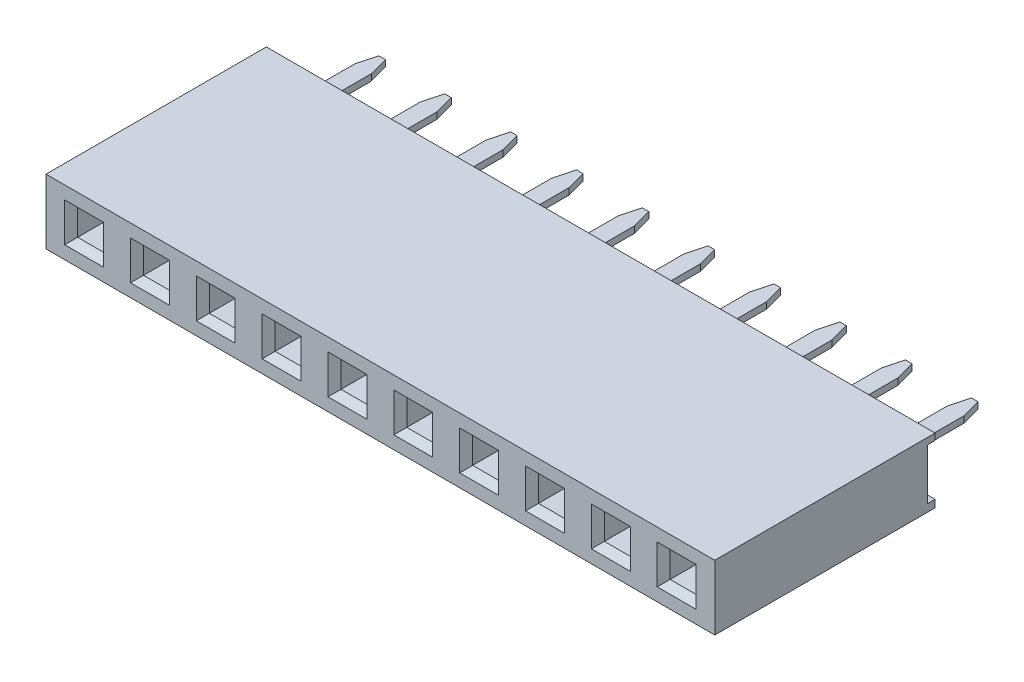
from build123d import *

# Parameters (mm, degrees)
SKETCH1_W                  = 25.8
SKETCH1_H                  = 2.5
BOSS_EXTRUDE1_DEPTH        = 8.5
SKETCH2_W                  = 1
SKETCH2_H                  = 1
CUT_EXTRUDE1_DEPTH         = 2.25
CHAMFER1_SIZE              = 0.25
SKETCH3_W                  = 0.3
SKETCH3_H                  = 1.963850618
CUT_EXTRUDE2_DEPTH         = 26.8
SKETCH4_W                  = 0.65
SKETCH4_H                  = 3.3
BOSS_EXTRUDE2_DEPTH        = 0.125
CHAMFER2_SIZE              = 0.2
CHAMFER2_SIZE2             = 0.746410162
LPATTERN4_COUNT            = 10
LPATTERN4_PITCH            = 2.54
LPATTERN5_COUNT            = 10
LPATTERN5_PITCH            = 2.54
CHAMFER1_OF_LPATTERN5_SIZE = 0.25


with BuildPart() as part:
    # Sketch1 → Boss-Extrude1 (new body)
    with BuildSketch(Plane.XY):
        with Locations((12.9, 1.25)):
            Rectangle(SKETCH1_W, SKETCH1_H)
    extrude(amount=BOSS_EXTRUDE1_DEPTH)

    # Sketch2 → Cut-Extrude1 (cut)
    with BuildSketch(Plane.XY.offset(8.5)):
        with Locations((1.47, 1.25)):
            Rectangle(SKETCH2_W, SKETCH2_H)
    cut_extrude1 = extrude(amount=-CUT_EXTRUDE1_DEPTH, mode=Mode.SUBTRACT)

    # Chamfer1
    chamfer1_edges = [part.edges().sort_by_distance(p)[0] for p in [
        (0.97, 1.25, 8.5),
        (1.47, 0.75, 8.5),
        (1.97, 1.25, 8.5),
        (1.47, 1.75, 8.5),
    ]]
    chamfer(chamfer1_edges, length=CHAMFER1_SIZE)

    # Sketch3 → Cut-Extrude2 (cut, through all)
    with BuildSketch(Plane.ZY):
        with Locations((0.15, 1.268074691)):
            Rectangle(SKETCH3_W, SKETCH3_H)
    extrude(amount=-CUT_EXTRUDE2_DEPTH, mode=Mode.SUBTRACT)

    # LPattern5: Cut-Extrude1 ×10
    with Locations(*[(i * LPATTERN5_PITCH, 0, 0) for i in range(1, LPATTERN5_COUNT)]):
        add(cut_extrude1, mode=Mode.SUBTRACT)

    # Chamfer1 of LPattern5
    chamfer1_of_lpattern5_edges = [part.edges().sort_by_distance(p)[0] for p in [
        (3.51, 1.25, 8.5),
        (4.01, 0.75, 8.5),
        (4.51, 1.25, 8.5),
        (4.01, 1.75, 8.5),
        (6.05, 1.25, 8.5),
        (6.55, 0.75, 8.5),
        (7.05, 1.25, 8.5),
        (6.55, 1.75, 8.5),
        (8.59, 1.25, 8.5),
        (9.09, 0.75, 8.5),
        (9.59, 1.25, 8.5),
        (9.09, 1.75, 8.5),
        (11.13, 1.25, 8.5),
        (11.63, 0.75, 8.5),
        (12.13, 1.25, 8.5),
        (11.63, 1.75, 8.5),
        (13.67, 1.25, 8.5),
        (14.17, 0.75, 8.5),
        (14.67, 1.25, 8.5),
        (14.17, 1.75, 8.5),
        (16.21, 1.25, 8.5),
        (16.71, 0.75, 8.5),
        (17.21, 1.25, 8.5),
        (16.71, 1.75, 8.5),
        (18.75, 1.25, 8.5),
        (19.25, 0.75, 8.5),
        (19.75, 1.25, 8.5),
        (19.25, 1.75, 8.5),
        (21.29, 1.25, 8.5),
        (21.79, 0.75, 8.5),
        (22.29, 1.25, 8.5),
        (21.79, 1.75, 8.5),
        (23.83, 1.25, 8.5),
        (24.33, 0.75, 8.5),
        (24.83, 1.25, 8.5),
        (24.33, 1.75, 8.5),
    ]]
    chamfer(chamfer1_of_lpattern5_edges, length=CHAMFER1_OF_LPATTERN5_SIZE)


with BuildPart() as body_2:
    # Sketch4 → Boss-Extrude2 (new body, symmetric)
    with BuildSketch(Plane(origin=(0, 1.25, 0), x_dir=(-1, 0, 0), z_dir=(0, -1, 0))):
        with Locations((-1.47, 1.35)):
            Rectangle(SKETCH4_W, SKETCH4_H)
    extrude(amount=BOSS_EXTRUDE2_DEPTH, both=True)

    # Chamfer2
    chamfer2_edges = [body_2.edges().sort_by_distance(p)[0] for p in [
        (1.795, 1.25, -3),
        (1.145, 1.25, -3),
    ]]
    chamfer2_side = [body_2.faces().sort_by_distance(p)[0] for p in [
        (1.47, 1.25, -3),
    ]]
    chamfer(chamfer2_edges, length=CHAMFER2_SIZE, length2=CHAMFER2_SIZE2, reference=chamfer2_side[0])


with BuildPart() as lpattern4_1:
    # LPattern4: pattern copy
    add(body_2.part.moved(Location(Vector(1, 0, 0) * (1 * LPATTERN4_PITCH))))


with BuildPart() as lpattern4_2:
    # LPattern4: pattern copy
    add(body_2.part.moved(Location(Vector(1, 0, 0) * (2 * LPATTERN4_PITCH))))


with BuildPart() as lpattern4_3:
    # LPattern4: pattern copy
    add(body_2.part.moved(Location(Vector(1, 0, 0) * (3 * LPATTERN4_PITCH))))


with BuildPart() as lpattern4_4:
    # LPattern4: pattern copy
    add(body_2.part.moved(Location(Vector(1, 0, 0) * (4 * LPATTERN4_PITCH))))


with BuildPart() as lpattern4_5:
    # LPattern4: pattern copy
    add(body_2.part.moved(Location(Vector(1, 0, 0) * (5 * LPATTERN4_PITCH))))


with BuildPart() as lpattern4_6:
    # LPattern4: pattern copy
    add(body_2.part.moved(Location(Vector(1, 0, 0) * (6 * LPATTERN4_PITCH))))


with BuildPart() as lpattern4_7:
    # LPattern4: pattern copy
    add(body_2.part.moved(Location(Vector(1, 0, 0) * (7 * LPATTERN4_PITCH))))


with BuildPart() as lpattern4_8:
    # LPattern4: pattern copy
    add(body_2.part.moved(Location(Vector(1, 0, 0) * (8 * LPATTERN4_PITCH))))


with BuildPart() as lpattern4_9:
    # LPattern4: pattern copy
    add(body_2.part.moved(Location(Vector(1, 0, 0) * (9 * LPATTERN4_PITCH))))


solid = Compound([part.part, body_2.part, lpattern4_1.part, lpattern4_2.part, lpattern4_3.part, lpattern4_4.part, lpattern4_5.part, lpattern4_6.part, lpattern4_7.part, lpattern4_8.part, lpattern4_9.part])
